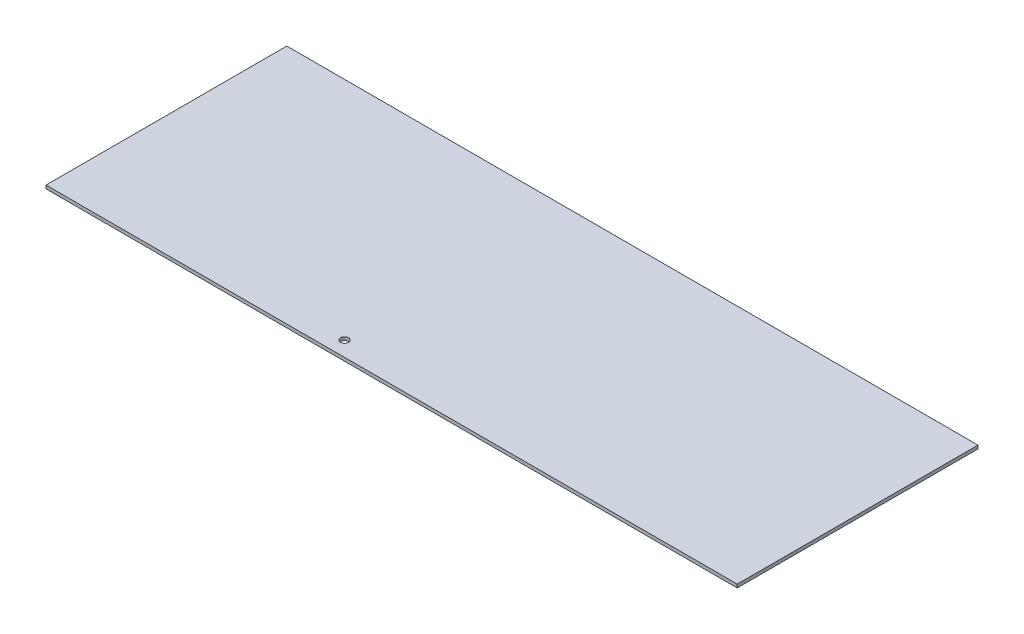
from build123d import *

# Parameters (mm, degrees)
SKETCH1_W           = 344.4875
SKETCH1_H           = 120
SKETCH1_R           = 2
BOSS_EXTRUDE1_DEPTH = 1.65


with BuildPart() as part:
    # Sketch1 → Boss-Extrude1 (new body)
    with BuildSketch(Plane(origin=(0, 0, 0), x_dir=(1, 0, 0), z_dir=(0, 1, 0))):
        with Locations((172.24375, 60)):
            Rectangle(SKETCH1_W, SKETCH1_H)
        with Locations((141.2875, 7.5)):
            Circle(SKETCH1_R, mode=Mode.SUBTRACT)
    extrude(amount=BOSS_EXTRUDE1_DEPTH)


solid = part.part
